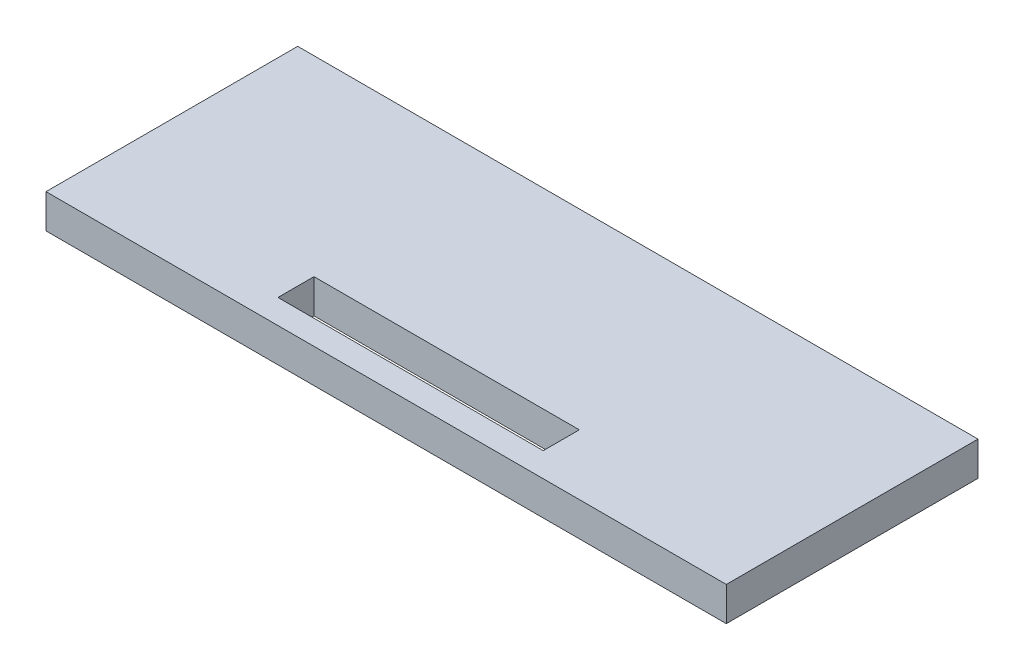
from build123d import *

# Parameters (mm, degrees)
CROQUIS1_W              = 100
CROQUIS1_H              = 4
SALIENTE_EXTRUIR1_DEPTH = 37
CROQUIS2_W              = 100
CROQUIS2_H              = 37
SALIENTE_EXTRUIR2_DEPTH = 1
CROQUIS3_W              = 39
CROQUIS3_H              = 5.3
CORTAR_EXTRUIR1_DEPTH   = 10


with BuildPart() as part:
    # Croquis1 → Saliente-Extruir1 (new body)
    with BuildSketch(Plane.XY):
        with Locations((-0.047455137, -88.502540378)):
            Rectangle(CROQUIS1_W, CROQUIS1_H)
    extrude(amount=SALIENTE_EXTRUIR1_DEPTH)

    # Croquis2 → Saliente-Extruir2 (add)
    with BuildSketch(Plane.XZ.offset(90.502540378)):
        with Locations((-0.047455137, 18.5)):
            Rectangle(CROQUIS2_W, CROQUIS2_H)
    extrude(amount=SALIENTE_EXTRUIR2_DEPTH)

    # Croquis3 → Cortar-Extruir1 (cut)
    with BuildSketch(Plane.XZ.offset(91.502540378)):
        with Locations((-0.030380106, 30.774409531)):
            Rectangle(CROQUIS3_W, CROQUIS3_H)
    extrude(amount=-CORTAR_EXTRUIR1_DEPTH, mode=Mode.SUBTRACT)


solid = part.part
